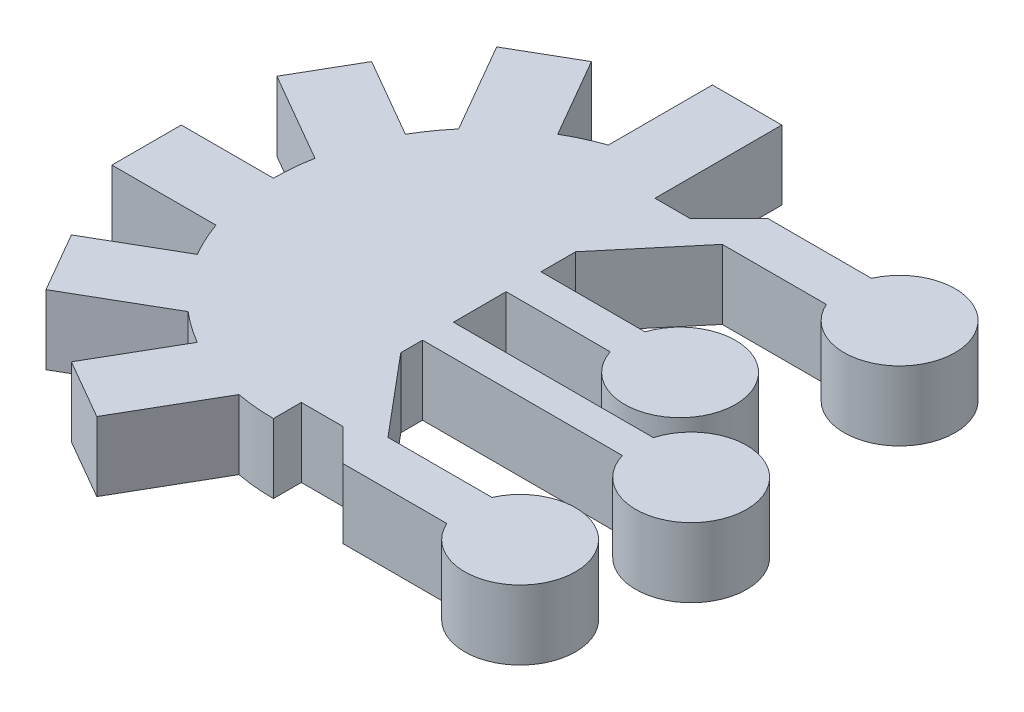
from build123d import *

# Parameters (mm, degrees)
BOSS_EXTRUDE1_DEPTH = 10


with BuildPart() as part:
    # Sketch1 → Boss-Extrude1 (new body)
    with BuildSketch(Plane(origin=(0, 0, 0), x_dir=(1, 0, 0), z_dir=(0, 1, 0))):
        with BuildLine():
            Line((-10, 43.284271247), (-10, 28.284271247))
            ThreePointArc((-10, 28.284271247), (-12.552949398, 27.247448714), (-15, 25.980762114))
            Line((-15, 25.980762114), (-21.642135624, 37.485278485))
            Line((-21.642135624, 37.485278485), (-30.302389662, 32.485278485))
            Line((-30.302389662, 32.485278485), (-22.802389662, 19.494897428))
            ThreePointArc((-22.802389662, 19.494897428), (-24.494897428, 17.320508076), (-25.980762114, 15))
            Line((-25.980762114, 15), (-37.485278485, 21.642135624))
            Line((-37.485278485, 21.642135624), (-42.485278485, 12.981881586))
            Line((-42.485278485, 12.981881586), (-29.494897428, 5.481881586))
            ThreePointArc((-29.494897428, 5.481881586), (-29.873457473, 2.752551286), (-30, 0))
            Line((-30, 0), (-43.284271247, 0))
            Line((-43.284271247, 0), (-43.284271247, -10))
            Line((-43.284271247, -10), (-28.284271247, -10))
            ThreePointArc((-28.284271247, -10), (-27.247448714, -12.552949398), (-25.980762114, -15))
            Line((-25.980762114, -15), (-37.485278485, -21.642135624))
            Line((-37.485278485, -21.642135624), (-32.485278485, -30.302389662))
            Line((-32.485278485, -30.302389662), (-19.494897428, -22.802389662))
            ThreePointArc((-19.494897428, -22.802389662), (-17.320508076, -24.494897428), (-15, -25.980762114))
            Line((-15, -25.980762114), (-21.642135624, -37.485278485))
            Line((-21.642135624, -37.485278485), (-12.981881586, -42.485278485))
            Line((-12.981881586, -42.485278485), (-5.481881586, -29.494897428))
            ThreePointArc((-5.481881586, -29.494897428), (-2.752551286, -29.873457473), (0, -30))
            Line((0, -30), (0, -25.980762114))
            Line((0, -25.980762114), (5.980762114, -25.980762114))
            Line((5.980762114, -25.980762114), (10.606601718, -30.606601718))
            Line((10.606601718, -30.606601718), (25.606601718, -30.606601718))
            ThreePointArc((25.606601718, -30.606601718), (40.914600616, -27.351889426), (25.606601718, -24.097177134))
            Line((25.606601718, -24.097177134), (10.606601718, -24.097177134))
            Line((10.606601718, -24.097177134), (0.964787573, -12.606510487))
            Line((0.964787573, -12.606510487), (0.959757824, -9.468981171))
            Line((0.959757824, -9.468981171), (29.777364974, -9.468981171))
            ThreePointArc((29.777364974, -9.468981171), (45.458969743, -7.234490585), (29.777364974, -5))
            Line((29.777364974, -5), (0.952593634, -5))
            Line((0.952593634, -5), (0.940399696, 2.606510487))
            Line((0.940399696, 2.606510487), (15.940399696, 2.606510487))
            ThreePointArc((15.940399696, 2.606510487), (31.551740371, 5.030424476), (15.964787573, 7.606510487))
            Line((15.964787573, 7.606510487), (0.964787573, 7.606510487))
            Line((0.964787573, 7.606510487), (0.964787573, 12.606510487))
            Line((0.964787573, 12.606510487), (10.606601718, 24.097177134))
            Line((10.606601718, 24.097177134), (25.606601718, 24.097177134))
            ThreePointArc((25.606601718, 24.097177134), (40.914600616, 27.351889426), (25.606601718, 30.606601718))
            Line((25.606601718, 30.606601718), (10.606601718, 30.606601718))
            Line((10.606601718, 30.606601718), (5, 25))
            Line((5, 25), (0, 25))
            Line((0, 25), (0, 30))
            Line((0, 30), (0, 43.284271247))
            Line((0, 43.284271247), (-10, 43.284271247))
        make_face()
    extrude(amount=BOSS_EXTRUDE1_DEPTH)


solid = part.part
